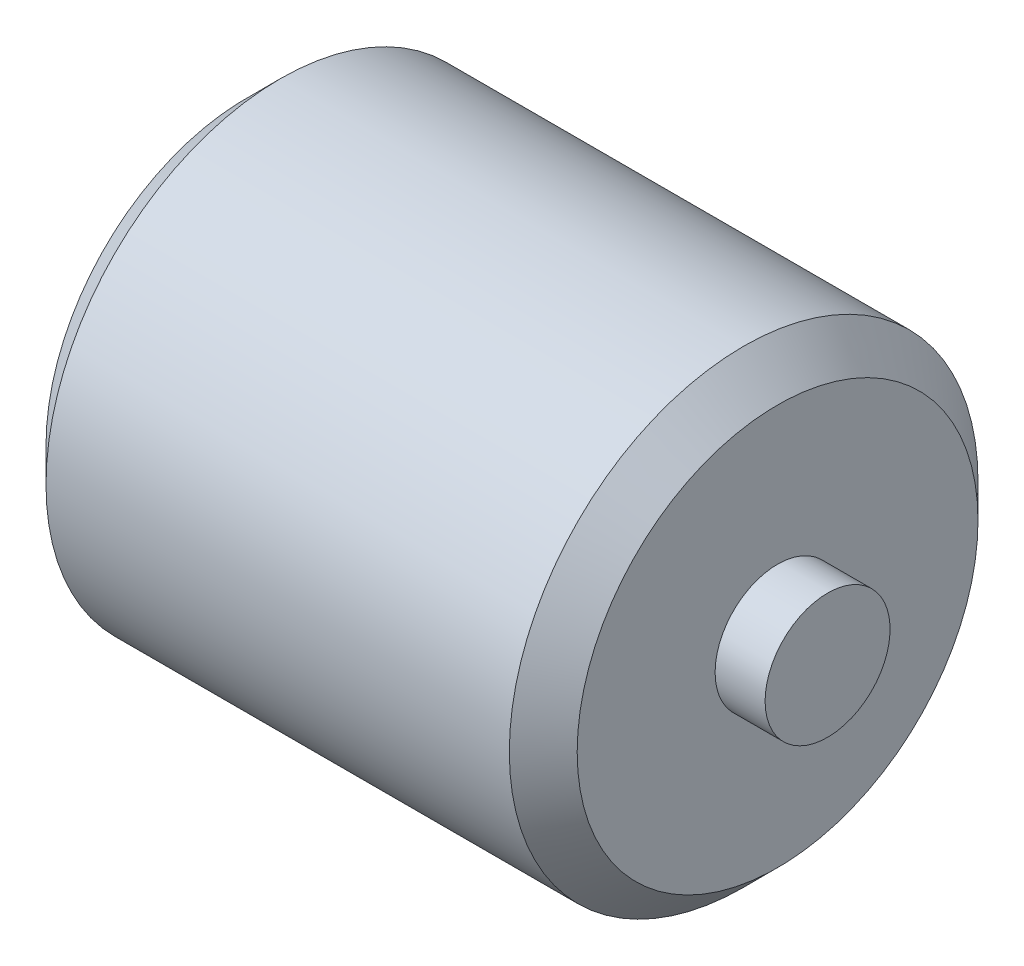
from build123d import *


with BuildPart() as part:
    # Croquis1 → Revolución-Lámina1 (revolve)
    with BuildSketch(Plane.XY):
        Polygon((182, 0), (182, 10), (166, 10), (166, 60), (161, 65), (21, 65), (16, 60), (16, 10), (0, 10), (0, 0), (-10, 0), (-10, 20), (6, 20), (6, 64.142135624), (16.857864376, 75), (165.142135624, 75), (176, 64.142135624), (176, 20), (192, 20), (192, 0), align=None)
    revolve(axis=Axis((0, 0, 0), (1, 0, 0)))


solid = part.part
